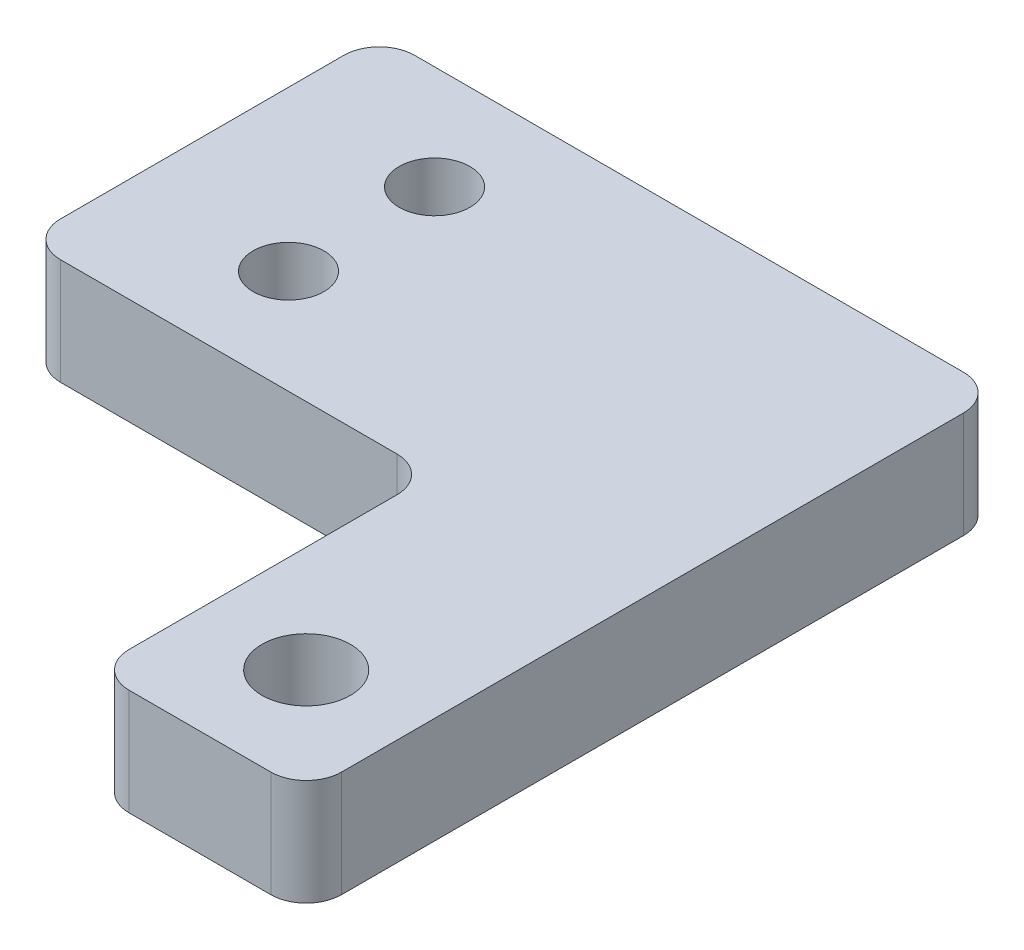
from build123d import *

# Parameters (mm, degrees)
SKETCH1_R           = 2
SKETCH1_R_2         = 2.5
BOSS_EXTRUDE1_DEPTH = 6
FILLET1_R           = 2


with BuildPart() as part:
    # Sketch1 → Boss-Extrude1 (new body)
    with BuildSketch(Plane(origin=(0, 0, 0), x_dir=(1, 0, 0), z_dir=(0, 1, 0))):
        Polygon((-9, 14.125), (-9, -5.875), (14, -5.875), (14, -25), (26, -25), (26, 14.125), align=None)
        with Locations((0, 8.25)):
            Circle(SKETCH1_R, mode=Mode.SUBTRACT)
        Circle(SKETCH1_R, mode=Mode.SUBTRACT)
        with Locations((20, -19)):
            Circle(SKETCH1_R_2, mode=Mode.SUBTRACT)
    extrude(amount=BOSS_EXTRUDE1_DEPTH)

    # Fillet1
    fillet1_edges = [part.edges().sort_by_distance(p)[0] for p in [
        (14, 3, 25),
        (14, 3, 5.875),
        (-9, 3, 5.875),
        (-9, 3, -14.125),
        (26, 3, -14.125),
        (26, 3, 25),
    ]]
    fillet(fillet1_edges, radius=FILLET1_R)


solid = part.part
